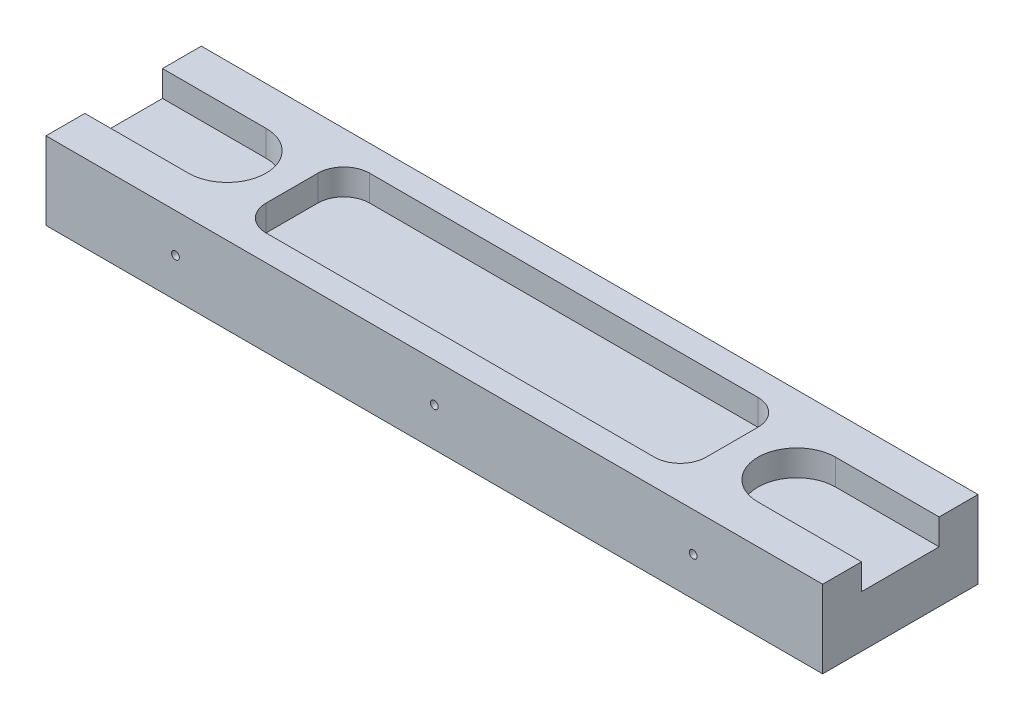
from build123d import *

# Parameters (mm, degrees)
SKETCH1_W           = 150
SKETCH1_H           = 30
BOSS_EXTRUDE1_DEPTH = 15
CUT_EXTRUDE1_DEPTH  = 5
SKETCH3_R           = 0.75
CUT_EXTRUDE2_DEPTH  = 30
CUT_EXTRUDE3_DEPTH  = 5


with BuildPart() as part:
    # Sketch1 → Boss-Extrude1 (new body)
    with BuildSketch(Plane(origin=(0, 0, 0), x_dir=(1, 0, 0), z_dir=(0, 1, 0))):
        with Locations((75, 15)):
            Rectangle(SKETCH1_W, SKETCH1_H)
    extrude(amount=BOSS_EXTRUDE1_DEPTH)

    # Sketch2 → Cut-Extrude1 (cut)
    with BuildSketch(Plane(origin=(0, 15, 0), x_dir=(1, 0, 0), z_dir=(0, 1, 0))):
        with BuildLine():
            Line((-20, 22.5), (20, 22.5))
            ThreePointArc((20, 22.5), (27.5, 15), (20, 7.5))
            Line((20, 7.5), (-20, 7.5))
            ThreePointArc((-20, 7.5), (-27.5, 15), (-20, 22.5))
        make_face()
        with BuildLine():
            Line((170, 22.5), (130, 22.5))
            ThreePointArc((130, 22.5), (122.5, 15), (130, 7.5))
            Line((130, 7.5), (170, 7.5))
            ThreePointArc((170, 7.5), (177.5, 15), (170, 22.5))
        make_face()
    extrude(amount=-CUT_EXTRUDE1_DEPTH, mode=Mode.SUBTRACT)

    # Sketch3 → Cut-Extrude2 (cut)
    with BuildSketch(Plane.XY):
        with Locations((25, 7.5)):
            Circle(SKETCH3_R)
        with Locations((75, 7.5)):
            Circle(SKETCH3_R)
        with Locations((125, 7.5)):
            Circle(SKETCH3_R)
    extrude(amount=-CUT_EXTRUDE2_DEPTH, mode=Mode.SUBTRACT)

    # Sketch4 → Cut-Extrude3 (cut)
    with BuildSketch(Plane(origin=(0, 15, 0), x_dir=(1, 0, 0), z_dir=(0, 1, 0))):
        with BuildLine():
            Line((37.5, 25), (112.5, 25))
            ThreePointArc((112.5, 25), (116.035533906, 23.535533906), (117.5, 20))
            Line((117.5, 20), (117.5, 10))
            ThreePointArc((117.5, 10), (116.035533906, 6.464466094), (112.5, 5))
            Line((112.5, 5), (37.5, 5))
            ThreePointArc((37.5, 5), (33.964466094, 6.464466094), (32.5, 10))
            Line((32.5, 10), (32.5, 20))
            ThreePointArc((32.5, 20), (33.964466094, 23.535533906), (37.5, 25))
        make_face()
    extrude(amount=-CUT_EXTRUDE3_DEPTH, mode=Mode.SUBTRACT)


solid = part.part
